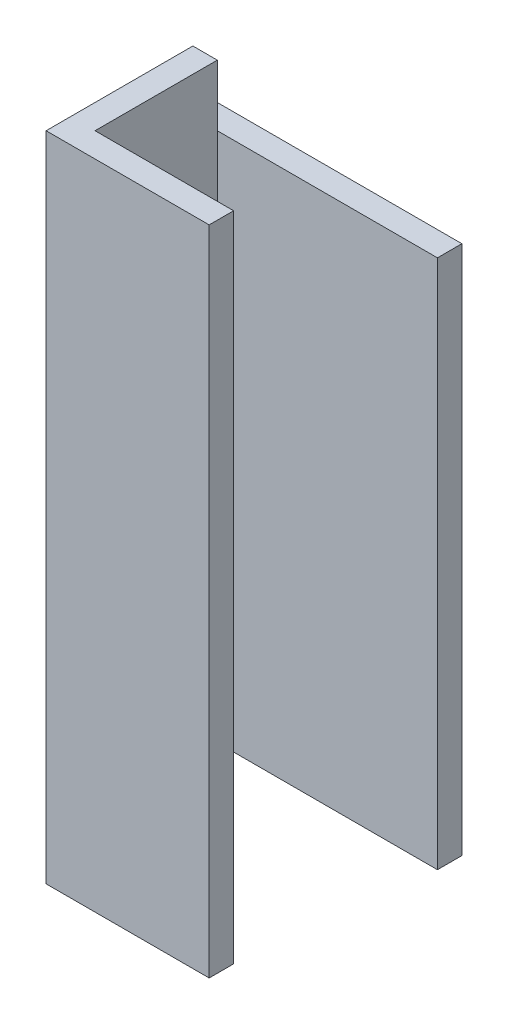
from build123d import *

# Parameters (mm, degrees)
SKETCH1_W           = 0.3
SKETCH1_H           = 0.21
BOSS_EXTRUDE1_DEPTH = 0.4
SKETCH2_W           = 0.27
SKETCH2_H           = 0.15
CUT_EXTRUDE1_DEPTH  = 1.8
SKETCH3_W           = 0.1
SKETCH3_H           = 0.03
CUT_EXTRUDE2_DEPTH  = 1.8
SKETCH4_W           = 0.3
SKETCH4_H           = 0.075
CUT_EXTRUDE3_DEPTH  = 0.03


with BuildPart() as part:
    # Sketch1 → Boss-Extrude1 (new body, symmetric)
    with BuildSketch(Plane(origin=(0, 0, 0), x_dir=(1, 0, 0), z_dir=(0, 1, 0))):
        with Locations((0.15, 0)):
            Rectangle(SKETCH1_W, SKETCH1_H)
    extrude(amount=BOSS_EXTRUDE1_DEPTH, both=True)

    # Sketch2 → Cut-Extrude1 (cut, through all)
    with BuildSketch(Plane.XZ.offset(0.4)):
        with Locations((0.165, 0)):
            Rectangle(SKETCH2_W, SKETCH2_H)
    extrude(amount=-CUT_EXTRUDE1_DEPTH, mode=Mode.SUBTRACT)

    # Sketch3 → Cut-Extrude2 (cut, through all)
    with BuildSketch(Plane.XZ.offset(0.4)):
        with Locations((0.25, 0.09)):
            Rectangle(SKETCH3_W, SKETCH3_H)
    extrude(amount=-CUT_EXTRUDE2_DEPTH, mode=Mode.SUBTRACT)

    # Sketch4 → Cut-Extrude3 (cut)
    with BuildSketch(Plane(origin=(0, 0, -0.105), x_dir=(-1, 0, 0), z_dir=(0, 0, -1))):
        with Locations((-0.15, -0.3625)):
            Rectangle(SKETCH4_W, SKETCH4_H)
    cut_extrude3 = extrude(amount=-CUT_EXTRUDE3_DEPTH, mode=Mode.SUBTRACT)

    # Mirror1: Cut-Extrude3 across plane
    add(cut_extrude3.mirror(Plane.ZX), mode=Mode.SUBTRACT)


solid = part.part
